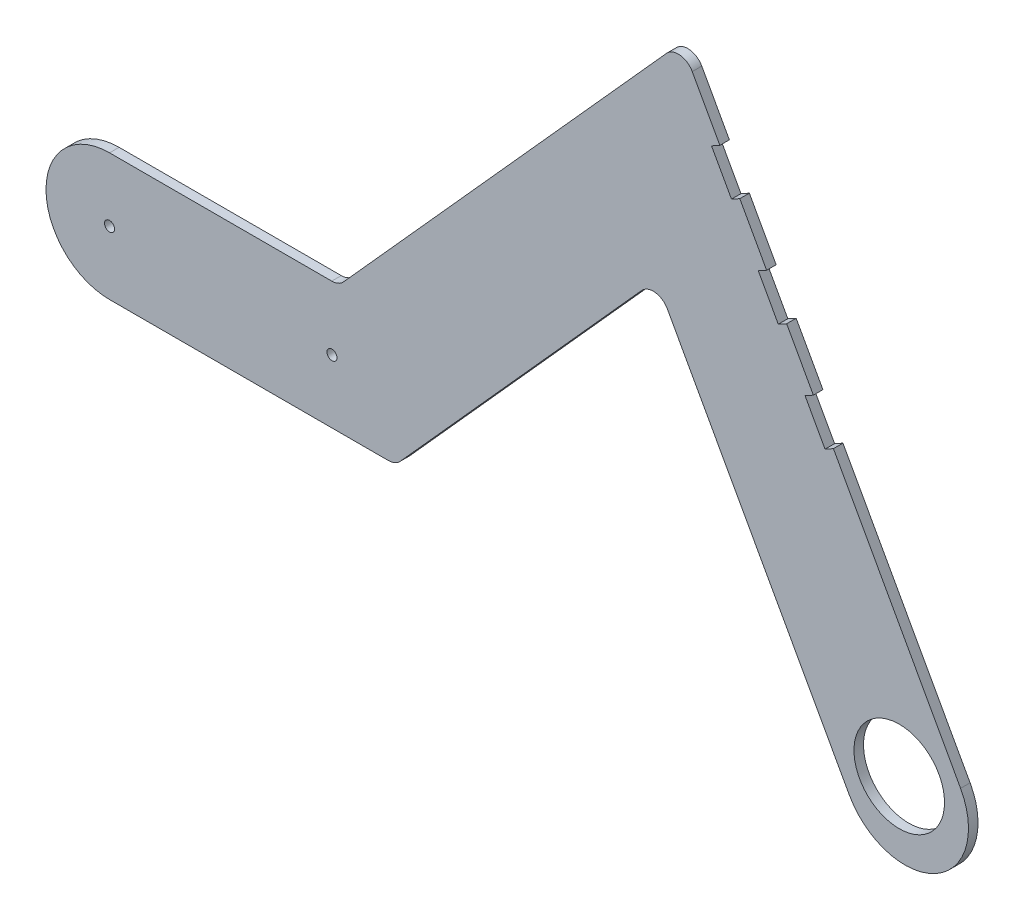
from build123d import *

# Parameters (mm, degrees)
CROQUIS1_R              = 1.58
CROQUIS1_R_2            = 14.25
SALIENTE_EXTRUIR1_DEPTH = 3
CROQUIS3_W              = 3
CROQUIS3_H              = 13.002457907
CROQUIS3_H_2            = 13.048194377
CROQUIS3_H_3            = 13.048194378
CORTAR_EXTRUIR1_DEPTH   = 3


with BuildPart() as part:
    # Croquis1 → Saliente-Extruir1 (new body)
    with BuildSketch(Plane.XY):
        with BuildLine():
            Line((-135.811178416, 31.660861846), (-65.873242367, 31.660861846))
            ThreePointArc((-65.873242367, 31.660861846), (-63.837291884, 32.094144685), (-62.154198363, 33.318899594))
            Line((-62.154198363, 33.318899594), (39.488020824, 146.429658271))
            ThreePointArc((39.488020824, 146.429658271), (43.775922453, 148.055230719), (47.585333219, 145.502393908))
            Line((47.585333219, 145.502393908), (132.043103592, -7.634273033))
            ThreePointArc((132.043103592, -7.634273033), (124.188821584, -34.806138154), (97.016956463, -26.951856146))
            Line((97.016956463, -26.951856146), (39.731279169, 76.917067288))
            ThreePointArc((39.731279169, 76.917067288), (35.921868403, 79.4699041), (31.633966774, 77.844331652))
            Line((31.633966774, 77.844331652), (-44.321252629, -6.681100406))
            ThreePointArc((-44.321252629, -6.681100406), (-46.00434615, -7.905855315), (-48.040296633, -8.339138154))
            Line((-48.040296633, -8.339138154), (-135.811178416, -8.339138154))
            ThreePointArc((-135.811178416, -8.339138154), (-155.811178416, 11.660861846), (-135.811178416, 31.660861846))
        make_face()
        with Locations((-135.811178416, 11.660861846)):
            Circle(CROQUIS1_R, mode=Mode.SUBTRACT)
        with Locations((-65.81121578, 11.5885363)):
            Circle(CROQUIS1_R, mode=Mode.SUBTRACT)
        with Locations((112.738617641, -14.044921514)):
            Circle(CROQUIS1_R_2, mode=Mode.SUBTRACT)
    extrude(amount=SALIENTE_EXTRUIR1_DEPTH)

    # Croquis3 → Cortar-Extruir1 (cut)
    with BuildSketch(Plane(origin=(98.018165522, 54.058873563, 0), x_dir=(0, 0, -1), z_dir=(0.875653678, 0.482939578, 0))):
        with Locations((-1.5, 79.927636726)):
            Rectangle(CROQUIS3_W, CROQUIS3_H)
        with Locations((-1.5, 49.42886568)):
            Rectangle(CROQUIS3_W, CROQUIS3_H_2)
        with Locations((-1.5, 18.952962868)):
            Rectangle(CROQUIS3_W, CROQUIS3_H_3)
    extrude(amount=-CORTAR_EXTRUIR1_DEPTH, mode=Mode.SUBTRACT)


solid = part.part
